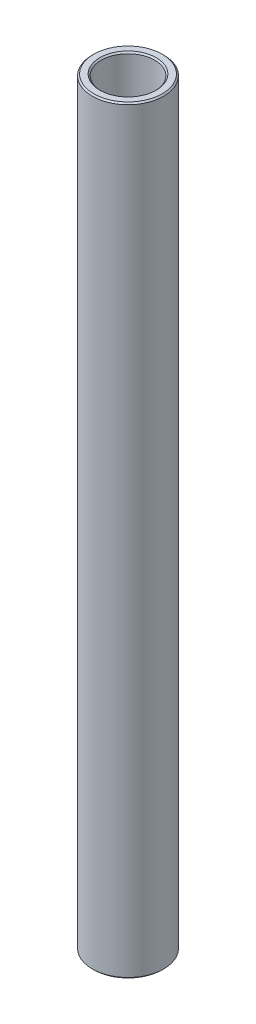
from build123d import *

# Parameters (mm, degrees)
SKETCH1_W     = 1.5875
SKETCH1_H     = 134.937947034
CHAMFER1_SIZE = 0.254


with BuildPart() as part:
    # Sketch1 → Revolve1 (revolve)
    with BuildSketch(Plane.XY):
        with Locations((5.55625, 138.112668482)):
            Rectangle(SKETCH1_W, SKETCH1_H)
    revolve(axis=Axis((0, 61.118694965, 0), (0, 1, 0)))

    # Chamfer1
    chamfer1_edges = [part.edges().sort_by_distance(p)[0] for p in [
        (-6.35, 70.643694965, 0),
        (-6.350000001, 205.581641999, 0),
        (-4.762500001, 205.581641999, 0),
        (-4.7625, 70.643694965, 0),
    ]]
    chamfer(chamfer1_edges, length=CHAMFER1_SIZE)


solid = part.part
